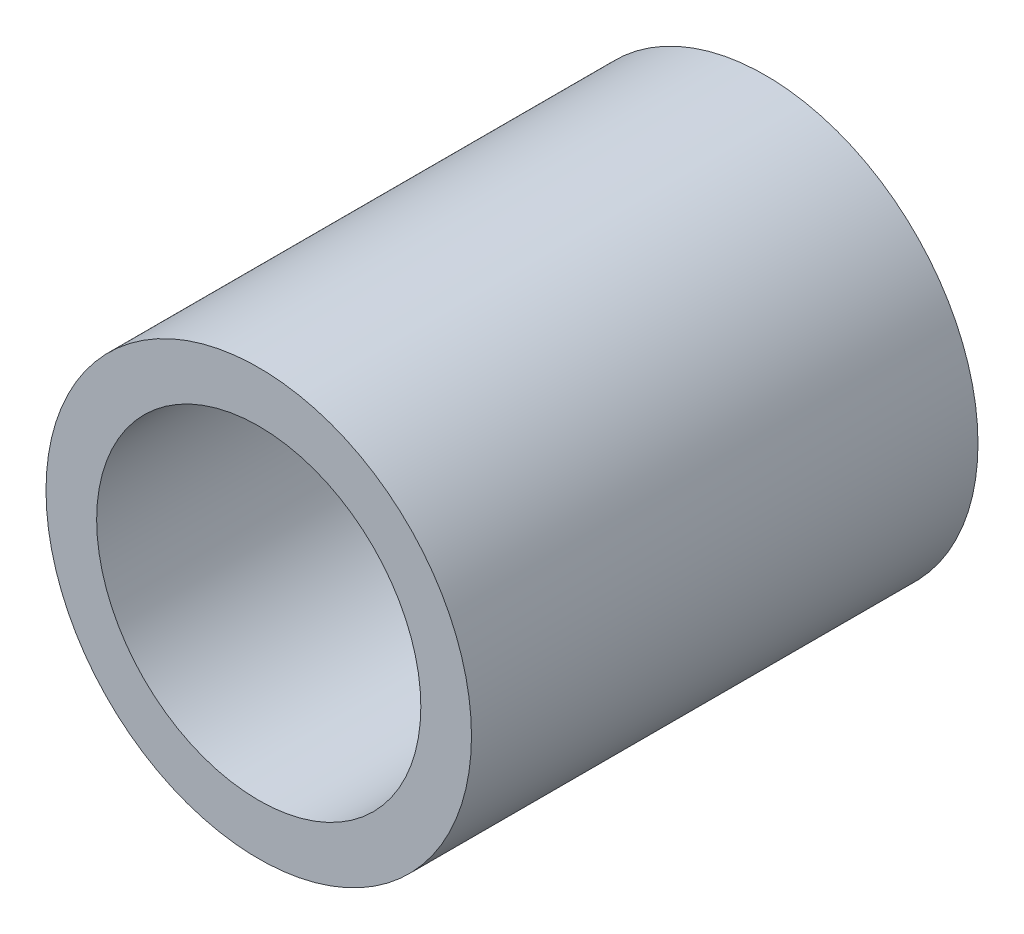
from build123d import *

# Parameters (mm, degrees)
SKETCH1_R           = 2.1
BOSS_EXTRUDE1_DEPTH = 5
SHELL1_T            = -0.5


with BuildPart() as part:
    # Sketch1 → Boss-Extrude1 (new body)
    with BuildSketch(Plane.XY):
        Circle(SKETCH1_R)
    extrude(amount=BOSS_EXTRUDE1_DEPTH)

    # Shell1
    shell1_openings = [part.faces().sort_by_distance(p)[0] for p in [
        (0, 0, 5),
        (0, 0, 0),
    ]]
    offset(amount=SHELL1_T, openings=shell1_openings, kind=Kind.INTERSECTION)


solid = part.part
